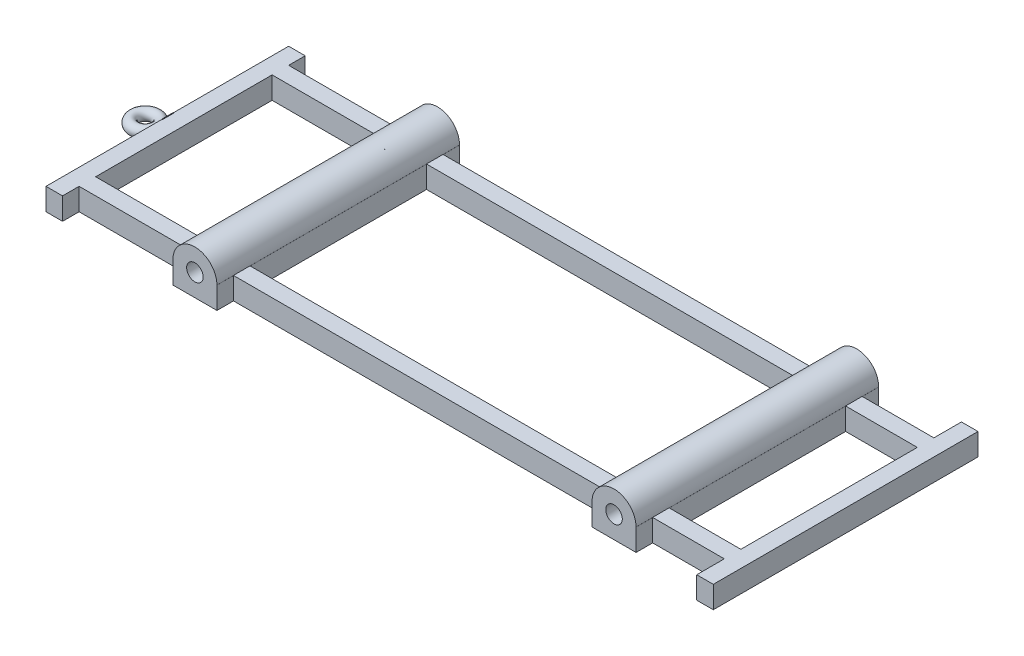
from build123d import *
from build123d.topology import SkipClean

# Parameters (mm, degrees)
SKETCH1_W           = 15
SKETCH1_H           = 220
SKETCH1_H_2         = 240
SKETCH1_W_2         = 585
SKETCH1_H_3         = 15
BOSS_EXTRUDE1_DEPTH = 20
BOSS_EXTRUDE2_DEPTH = 110
SKETCH3_R           = 7.5
CUT_EXTRUDE1_DEPTH  = 471.046447738
SKETCH9_R           = 5
BOSS_EXTRUDE3_DEPTH = 5
BOSS_EXTRUDE4_DEPTH = 10


with BuildPart() as part:
    # Sketch1 → Boss-Extrude1 (new body)
    with BuildSketch(Plane(origin=(0, 0, 0), x_dir=(1, 0, 0), z_dir=(0, 1, 0))):
        with Locations((-199.513888889, 0)):
            Rectangle(SKETCH1_W, SKETCH1_H)
        with Locations((400.486111111, 0)):
            Rectangle(SKETCH1_W, SKETCH1_H_2)
        with Locations((100.486111111, -87.5)):
            Rectangle(SKETCH1_W_2, SKETCH1_H_3)
        with Locations((100.486111111, 87.5)):
            Rectangle(SKETCH1_W_2, SKETCH1_H_3)
    extrude(amount=BOSS_EXTRUDE1_DEPTH)

    # Sketch2 → Boss-Extrude2 (add, symmetric)
    with BuildSketch(Plane.XY):
        with BuildLine():
            Line((327.929757791, 19.943646679), (327.986111111, 19.943646679))
            Line((327.986111111, 19.943646679), (327.986111111, 0))
            Line((327.986111111, 0), (287.986111111, 0))
            Line((287.986111111, 0), (287.986111111, 19.943646679))
            Line((287.986111111, 19.943646679), (288.042464432, 19.943646679))
            ThreePointArc((288.042464432, 19.943646679), (307.986111111, 39.887293359), (327.929757791, 19.943646679))
        make_face()
        with BuildLine():
            Line((-92.013888889, 0), (-52.013888889, 0))
            Line((-52.013888889, 0), (-52.013888889, 19.943646679))
            Line((-52.013888889, 19.943646679), (-52.070242209, 19.943646679))
            ThreePointArc((-52.070242209, 19.943646679), (-72.013888889, 39.887293359), (-91.957535568, 19.943646679))
            Line((-91.957535568, 19.943646679), (-92.013888889, 19.943646679))
            Line((-92.013888889, 19.943646679), (-92.013888889, 0))
        make_face()
    extrude(amount=BOSS_EXTRUDE2_DEPTH, both=True)

    # Sketch3 → Cut-Extrude1 (cut, through all)
    with BuildSketch(Plane(origin=(0, 0, -110), x_dir=(-1, 0, 0), z_dir=(0, 0, -1))):
        with Locations((72.013888889, 19.943646679)):
            Circle(SKETCH3_R)
        with Locations((-307.986111111, 19.943646679)):
            Circle(SKETCH3_R)
    extrude(amount=-CUT_EXTRUDE1_DEPTH, mode=Mode.SUBTRACT)



with BuildPart() as body_2:
    # Sketch9 → Revolve1 (revolve)
    with BuildSketch(Plane.XY, mode=Mode.PRIVATE) as revolve1_sk:
        with Locations((-237.013888889, 5)):
            Circle(SKETCH9_R)
    revolve(revolve1_sk.sketch.rotate(Axis((-227.013888889, 0, 0), (0, 1, 0)), 270), axis=Axis((-227.013888889, 0, 0), (0, 1, 0)))


with BuildPart() as part_1:
    with SkipClean():  # the faces are left unmerged after this step: merging them gives an invalid solid
        add(part.part)

        add(body_2.part)  # Boss-Extrude3 merges body 2
        # Sketch12 → Boss-Extrude3 (add, symmetric)
        with BuildSketch(Plane.XY):
            Polygon((-206.542026968, 0.242112027), (-216.880044211, 0.230191772), (-206.565640886, 20.721631917), align=None)
        extrude(amount=BOSS_EXTRUDE3_DEPTH, both=True)

    # Sketch7 → Boss-Extrude4 (add)
    with SkipClean():  # the faces are left unmerged after this step: merging them gives an invalid solid
        with BuildSketch(Plane(origin=(0, 0, 0), x_dir=(-1, 0, 0), z_dir=(0, -1, 0))):
            with BuildLine():
                Line((77.013888889, 30), (77.013888889, -30))
                ThreePointArc((77.013888889, -30), (72.013888889, -35), (67.013888889, -30))
                Line((67.013888889, -30), (67.013888889, 30))
                ThreePointArc((67.013888889, 30), (72.013888889, 35), (77.013888889, 30))
            make_face()
            with BuildLine():
                Line((-302.986111111, 30), (-302.986111111, -30))
                ThreePointArc((-302.986111111, -30), (-307.986111111, -35), (-312.986111111, -30))
                Line((-312.986111111, -30), (-312.986111111, 30))
                ThreePointArc((-312.986111111, 30), (-307.986111111, 35), (-302.986111111, 30))
            make_face()
        extrude(amount=BOSS_EXTRUDE4_DEPTH)


solid = part_1.part
